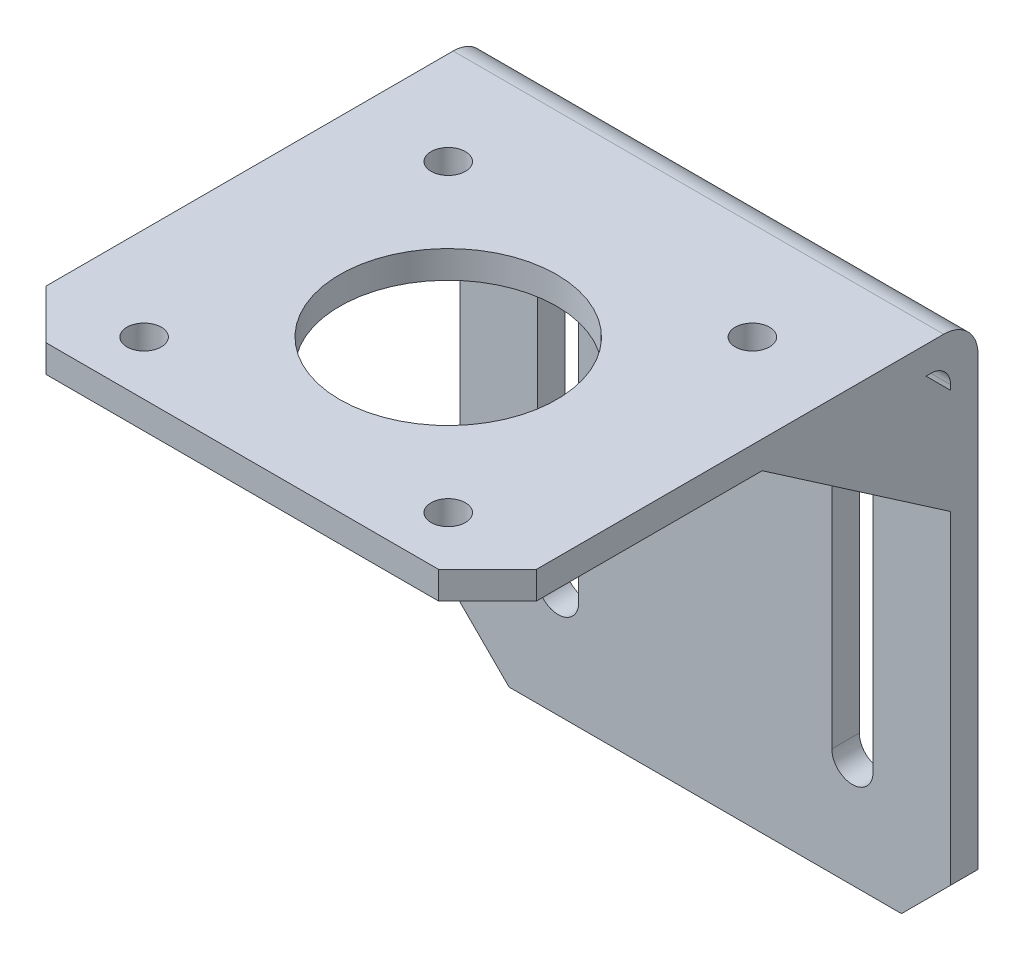
from build123d import *

# Parameters (mm, degrees)
BOSS_EXTRUDE1_DEPTH      = 25
BOSS_EXTRUDE1_DEPTH_BACK = 25
SKETCH3_R                = 11.05
SKETCH3_R_2              = 1.75
CUT_EXTRUDE1_DEPTH       = 78.723870207
CUT_EXTRUDE2_DEPTH       = 78.723870207
CHAMFER1_SIZE            = 5
FILLET1_R                = 2
FILLET2_R                = 3.5
BOSS_EXTRUDE2_DEPTH      = 2.5
SKETCH6_R                = 3.175
BOSS_EXTRUDE3_DEPTH      = 15


with BuildPart() as part:
    # Sketch1 → Boss-Extrude1 (new, two sides: drawn at the far end of the back side and taken through both)
    with BuildSketch(Plane(origin=(0, 0, 0), x_dir=(0, 0, -1), z_dir=(1, 0, 0)).offset(-BOSS_EXTRUDE1_DEPTH_BACK)):
        Polygon((-50, 0), (-50, -2.8), (-2.8, -2.8), (-2.8, -54), (0, -54), (0, 0), align=None)
    extrude(amount=BOSS_EXTRUDE1_DEPTH + BOSS_EXTRUDE1_DEPTH_BACK)

    # Sketch3 → Cut-Extrude1 (cut, through all)
    with BuildSketch(Plane(origin=(0, 0, 0), x_dir=(1, 0, 0), z_dir=(0, 1, 0))):
        with Locations((0, -29)):
            Circle(SKETCH3_R)
        with Locations((-15.5, -13.5)):
            Circle(SKETCH3_R_2)
        with Locations((15.5, -13.5)):
            Circle(SKETCH3_R_2)
        with Locations((15.5, -44.5)):
            Circle(SKETCH3_R_2)
        with Locations((-15.5, -44.5)):
            Circle(SKETCH3_R_2)
    extrude(amount=-CUT_EXTRUDE1_DEPTH, mode=Mode.SUBTRACT)

    # Sketch4 → Cut-Extrude2 (cut, through all)
    with BuildSketch(Plane(origin=(0, 0, 0), x_dir=(-1, 0, 0), z_dir=(0, 0, -1))):
        with BuildLine():
            Line((-17.1, -43), (-17.1, -13))
            ThreePointArc((-17.1, -13), (-15, -10.9), (-12.9, -13))
            Line((-12.9, -13), (-12.9, -43))
            ThreePointArc((-12.9, -43), (-15, -45.1), (-17.1, -43))
        make_face()
        with BuildLine():
            Line((12.9, -43), (12.9, -13))
            ThreePointArc((12.9, -13), (15, -10.9), (17.1, -13))
            Line((17.1, -13), (17.1, -43))
            ThreePointArc((17.1, -43), (15, -45.1), (12.9, -43))
        make_face()
    extrude(amount=-CUT_EXTRUDE2_DEPTH, mode=Mode.SUBTRACT)

    # Chamfer1
    chamfer1_edges = [part.edges().sort_by_distance(p)[0] for p in [
        (25, -54, 1.4),
        (-25, -54, 1.4),
        (-25, -1.4, 50),
        (25, -1.4, 50),
    ]]
    chamfer(chamfer1_edges, length=CHAMFER1_SIZE)

    # Fillet1
    fillet1_edges = [part.edges().sort_by_distance(p)[0] for p in [
        (0, -2.8, 2.8),
    ]]
    fillet(fillet1_edges, radius=FILLET1_R)

    # Fillet2
    fillet2_edges = [part.edges().sort_by_distance(p)[0] for p in [
        (0, 0, 0),
    ]]
    fillet(fillet2_edges, radius=FILLET2_R)

    # Sketch5 → Boss-Extrude2 (add)
    with BuildSketch(Plane.ZY.offset(25)):
        Polygon((2.8, -5.3), (5.3, -2.8), (22, -2.8), (2.8, -16), align=None)
    boss_extrude2 = extrude(amount=-BOSS_EXTRUDE2_DEPTH)

    # Mirror1: Boss-Extrude2 across plane
    add(boss_extrude2.mirror(Plane(origin=(0, 0, 0), x_dir=(0, 0, 1), z_dir=(1, 0, 0))))

    # Sketch6 → Boss-Extrude3 (add)
    with BuildSketch(Plane.XY.offset(2.8)):
        with Locations((0, -29)):
            Circle(SKETCH6_R)
    extrude(amount=-BOSS_EXTRUDE3_DEPTH)


solid = part.part
